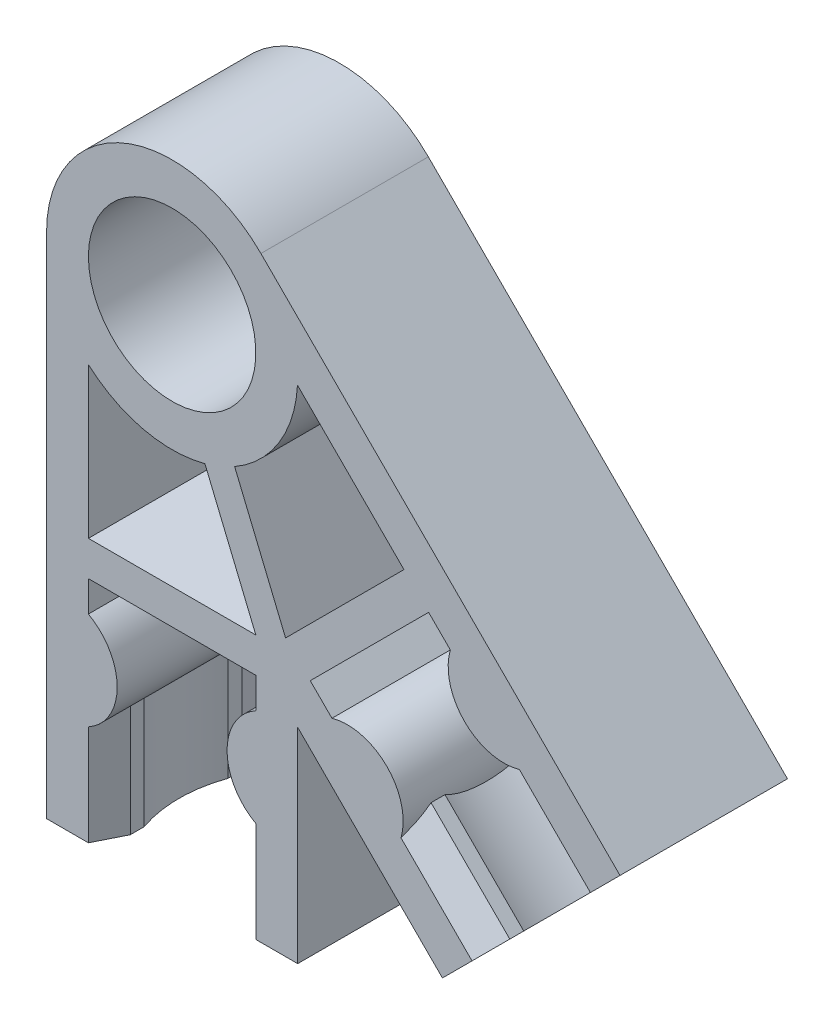
from build123d import *

# Parameters (mm, degrees)
EXTRUDE_1_DEPTH          = 6
EXTRUDE_2_REACH          = 25.907
PATTERN_CIRCULAR_1_COUNT = 2
PATTERN_CIRCULAR_1_ANGLE = 45
SKETCH_4_R               = 3
CUT_EXTRUDE_2_DEPTH      = 25.997699991


with BuildPart() as part:
    # 草图1 → 凸台-拉伸1 (new body)
    with BuildSketch(Plane.XY):
        with BuildLine():
            Line((-4.5, 0), (-4.5, -18.2))
            Line((-4.5, -18.2), (-3, -18.2))
            Line((-3, -18.2), (-3, -14.6))
            ThreePointArc((-3, -14.6), (-1.968245837, -12.85), (-3, -11.1))
            Line((-3, -11.1), (-3, -10))
            Line((-3, -10), (3, -10))
            Line((3, -10), (3, -11.1))
            ThreePointArc((3, -11.1), (1.968245837, -12.85), (3, -14.6))
            Line((3, -14.6), (3, -18.2))
            Line((3, -18.2), (4.5, -18.2))
            Line((4.5, -18.2), (4.5, 0))
            ThreePointArc((4.5, 0), (0, 4.5), (-4.5, 0))
        make_face()
    extrude_1 = extrude(amount=EXTRUDE_1_DEPTH)

    # 草图3 → 凸台-拉伸2 (add, up to next)
    with BuildSketch(Plane.XZ.offset(18.2), mode=Mode.PRIVATE) as extrude_2_sk1:
        with BuildLine():
            Line((-3, 6), (-3, 0))
            Line((-3, 0), (-2.5, 1))
            Line((-2.5, 1), (-2.5, 1.5))
            ThreePointArc((-2.5, 1.5), (-2.757359313, 3), (-2.5, 4.5))
            Line((-2.5, 4.5), (-2.5, 5))
            Line((-2.5, 5), (-3, 6))
        make_face()
    extrude_2_tool1 = extrude(extrude_2_sk1.sketch, amount=-EXTRUDE_2_REACH, mode=Mode.PRIVATE) - part.part
    # 草图3 → 凸台-拉伸2 (add, up to next)
    with BuildSketch(Plane.XZ.offset(18.2), mode=Mode.PRIVATE) as extrude_2_sk2:
        with BuildLine():
            Line((3, 0), (2.5, 1))
            Line((2.5, 1), (2.5, 1.5))
            ThreePointArc((2.5, 1.5), (2.757359313, 3), (2.5, 4.5))
            Line((2.5, 4.5), (2.5, 5))
            Line((2.5, 5), (3, 6))
            Line((3, 6), (3, 0))
        make_face()
    extrude_2_tool2 = extrude(extrude_2_sk2.sketch, amount=-EXTRUDE_2_REACH, mode=Mode.PRIVATE) - part.part
    extrude_2_1 = extrude_2_tool1.solids().sort_by_distance((-2.809362, -18.2, 3))[0]
    add(extrude_2_1)
    extrude_2_2 = extrude_2_tool2.solids().sort_by_distance((2.809362, -18.2, 3))[0]
    add(extrude_2_2)
    extrude_2 = extrude_2_1 + extrude_2_2  # 凸台-拉伸2 as one shape, for the pattern or mirror that repeats it

    # 阵列(圆周)1: 凸台-拉伸1, 凸台-拉伸2 ×2 about axis
    pattern_circular_1_axis = Axis((0, 0, 0), (0, 0, 1))
    add([extrude_1.rotate(pattern_circular_1_axis, i * PATTERN_CIRCULAR_1_ANGLE / (PATTERN_CIRCULAR_1_COUNT - 1)) for i in range(1, PATTERN_CIRCULAR_1_COUNT)])
    add([extrude_2.rotate(pattern_circular_1_axis, i * PATTERN_CIRCULAR_1_ANGLE / (PATTERN_CIRCULAR_1_COUNT - 1)) for i in range(1, PATTERN_CIRCULAR_1_COUNT)])

    # 草图4 → 切除-拉伸2 (cut, through all)
    with BuildSketch(Plane(origin=(0, 0, 0), x_dir=(-1, 0, 0), z_dir=(0, 0, -1))):
        Circle(SKETCH_4_R)
        with BuildLine():
            Line((3, -8.75), (3, -3.354101966))
            ThreePointArc((3, -3.354101966), (1.038095674, -4.378625055), (-1.174936357, -4.343906601))
            Line((-1.174936357, -4.343906601), (-3, -8.75))
            Line((-3, -8.75), (3, -8.75))
        make_face()
        with BuildLine():
            Line((-8.308504679, -4.065863992), (-4.493028589, -0.250387902))
            ThreePointArc((-4.493028589, -0.250387902), (-3.830199959, -2.362110978), (-2.240800349, -3.90241128))
            Line((-2.240800349, -3.90241128), (-4.065863992, -8.308504679))
            Line((-4.065863992, -8.308504679), (-8.308504679, -4.065863992))
        make_face()
    extrude(amount=-CUT_EXTRUDE_2_DEPTH, mode=Mode.SUBTRACT)


solid = part.part
